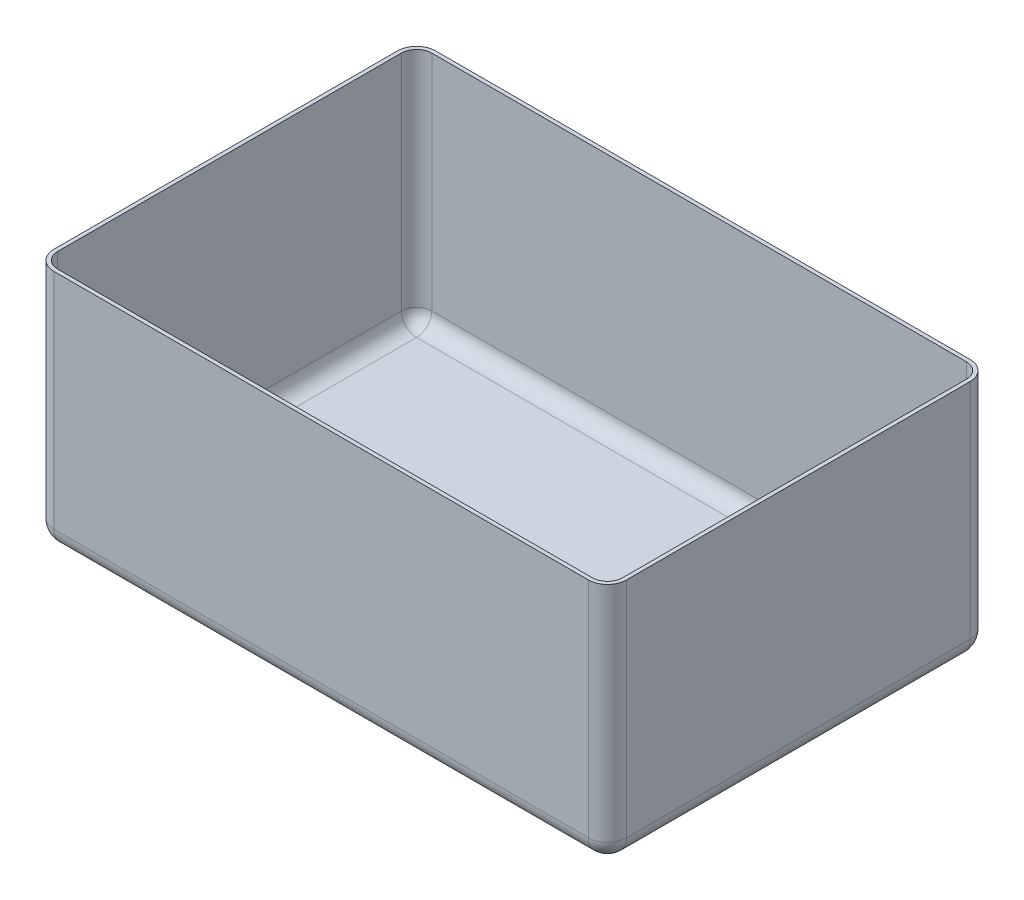
from build123d import *

# Parameters (mm, degrees)
SKETCH1_W           = 300
SKETCH1_H           = 200
BOSS_EXTRUDE1_DEPTH = 127
FILLET1_R           = 10
SHELL1_T            = -2


with BuildPart() as part:
    # Sketch1 → Boss-Extrude1 (new body)
    with BuildSketch(Plane(origin=(0, 0, 0), x_dir=(1, 0, 0), z_dir=(0, 1, 0))):
        Rectangle(SKETCH1_W, SKETCH1_H)
    extrude(amount=BOSS_EXTRUDE1_DEPTH)

    # Fillet1
    fillet1_edges = [part.edges().sort_by_distance(p)[0] for p in [
        (150, 0, 0),
        (0, 0, 100),
        (-150, 0, 0),
        (0, 0, -100),
        (150, 63.5, -100),
        (150, 63.5, 100),
        (-150, 63.5, 100),
        (-150, 63.5, -100),
    ]]
    fillet(fillet1_edges, radius=FILLET1_R)

    # Shell1
    shell1_openings = [part.faces().sort_by_distance(p)[0] for p in [
        (0, 127, 0),
    ]]
    offset(amount=SHELL1_T, openings=shell1_openings, kind=Kind.INTERSECTION)


solid = part.part
